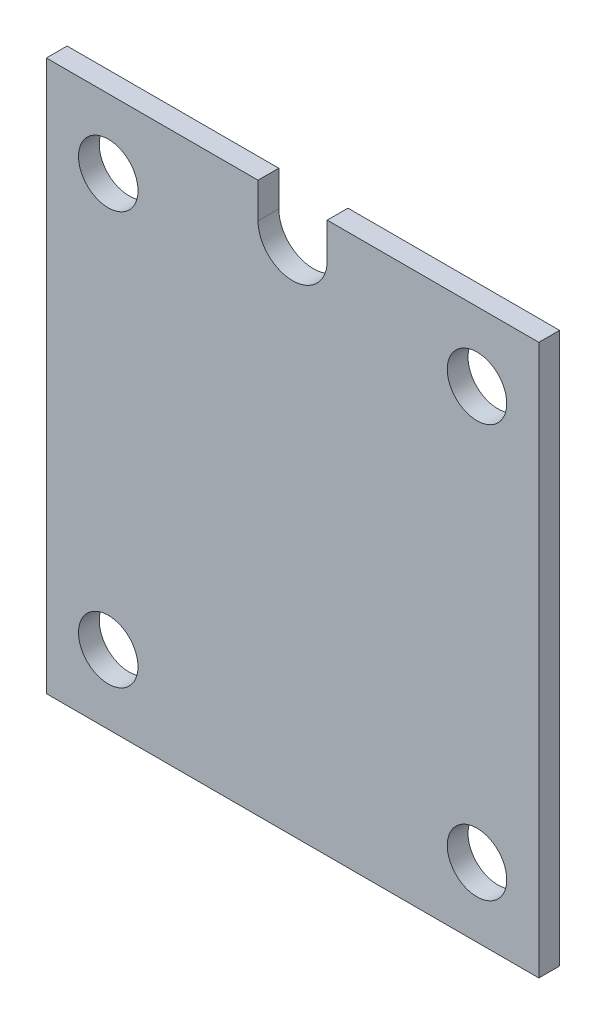
from build123d import *

# Parameters (mm, degrees)
SKETCH1_R           = 4.3
BOSS_EXTRUDE1_DEPTH = 3


with BuildPart() as part:
    # Sketch1 → Boss-Extrude1 (new body)
    with BuildSketch(Plane.XY):
        with BuildLine():
            Line((-35.59279418, 39.784944199), (-35.59279418, -39.784944199))
            Line((-35.59279418, -39.784944199), (35.59279418, -39.784944199))
            Line((35.59279418, -39.784944199), (35.59279418, 39.784944199))
            Line((35.59279418, 39.784944199), (5, 39.784944199))
            Line((5, 39.784944199), (5, 34.7))
            ThreePointArc((5, 34.7), (0, 29.7), (-5, 34.7))
            Line((-5, 34.7), (-5, 39.784944199))
            Line((-5, 39.784944199), (-35.59279418, 39.784944199))
        make_face()
        with Locations((-26.65, -29.8)):
            Circle(SKETCH1_R, mode=Mode.SUBTRACT)
        with Locations((26.65, -29.8)):
            Circle(SKETCH1_R, mode=Mode.SUBTRACT)
        with Locations((-26.65, 29.8)):
            Circle(SKETCH1_R, mode=Mode.SUBTRACT)
        with Locations((26.65, 29.8)):
            Circle(SKETCH1_R, mode=Mode.SUBTRACT)
    extrude(amount=BOSS_EXTRUDE1_DEPTH)


solid = part.part
